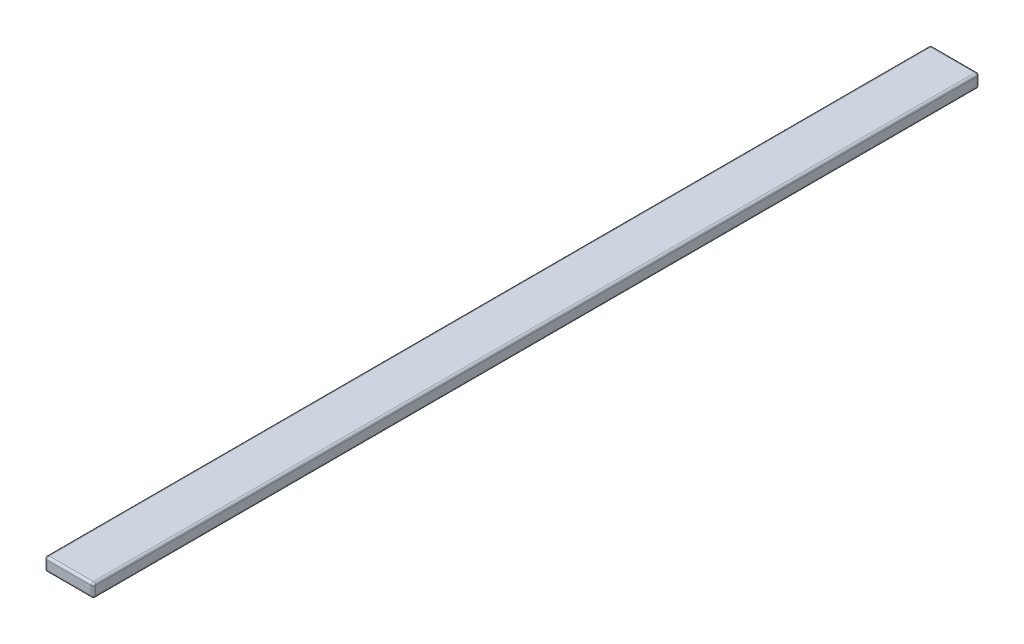
from build123d import *

# Parameters (mm, degrees)
SKETCH1_W           = 22
SKETCH1_H           = 6
BOSS_EXTRUDE1_DEPTH = 400
FILLET1_R           = 1


with BuildPart() as part:
    # Sketch1 → Boss-Extrude1 (new body)
    with BuildSketch(Plane.XY):
        Rectangle(SKETCH1_W, SKETCH1_H)
    extrude(amount=BOSS_EXTRUDE1_DEPTH)

    # Fillet1
    fillet1_edges = [part.edges().sort_by_distance(p)[0] for p in [
        (-11, 0, 400),
        (0, -3, 400),
        (11, 0, 400),
        (0, -3, 0),
        (-11, 0, 0),
        (0, 3, 0),
        (11, 0, 0),
        (0, 3, 400),
        (11, -3, 200),
        (-11, -3, 200),
        (-11, 3, 200),
        (11, 3, 200),
    ]]
    fillet(fillet1_edges, radius=FILLET1_R)


solid = part.part
